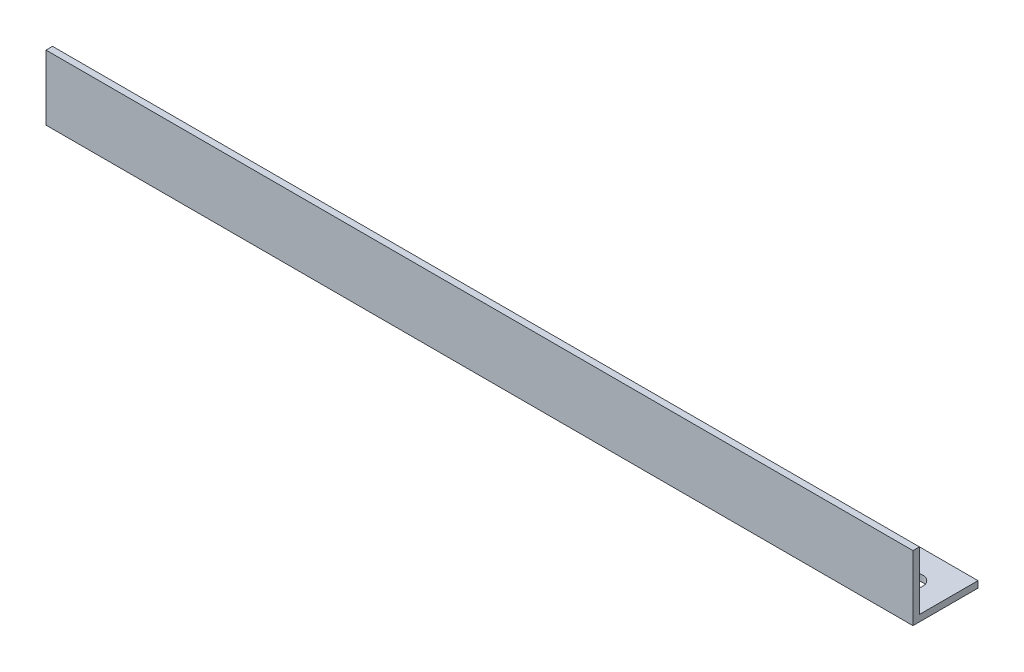
from build123d import *

# Parameters (mm, degrees)
EXTRUDE_1_DEPTH     = 200
SKETCH_2_R          = 2.25
CUT_EXTRUDE_1_DEPTH = 16


with BuildPart() as part:
    # Эскиз1 → Бобышка-Вытянуть1 (new body)
    with BuildSketch(Plane(origin=(0, 0, 0), x_dir=(0, 0, -1), z_dir=(1, 0, 0))):
        Polygon((0, 0), (0, 15), (1.5, 15), (1.5, 1.5), (15, 1.5), (15, 0), align=None)
    extrude(amount=EXTRUDE_1_DEPTH)

    # Эскиз2 → Вырез-Вытянуть1 (cut, through all)
    with BuildSketch(Plane.XZ):
        with Locations((7.5, -7.5)):
            Circle(SKETCH_2_R)
        with Locations((192.5, -7.5)):
            Circle(SKETCH_2_R)
    extrude(amount=-CUT_EXTRUDE_1_DEPTH, mode=Mode.SUBTRACT)


solid = part.part
